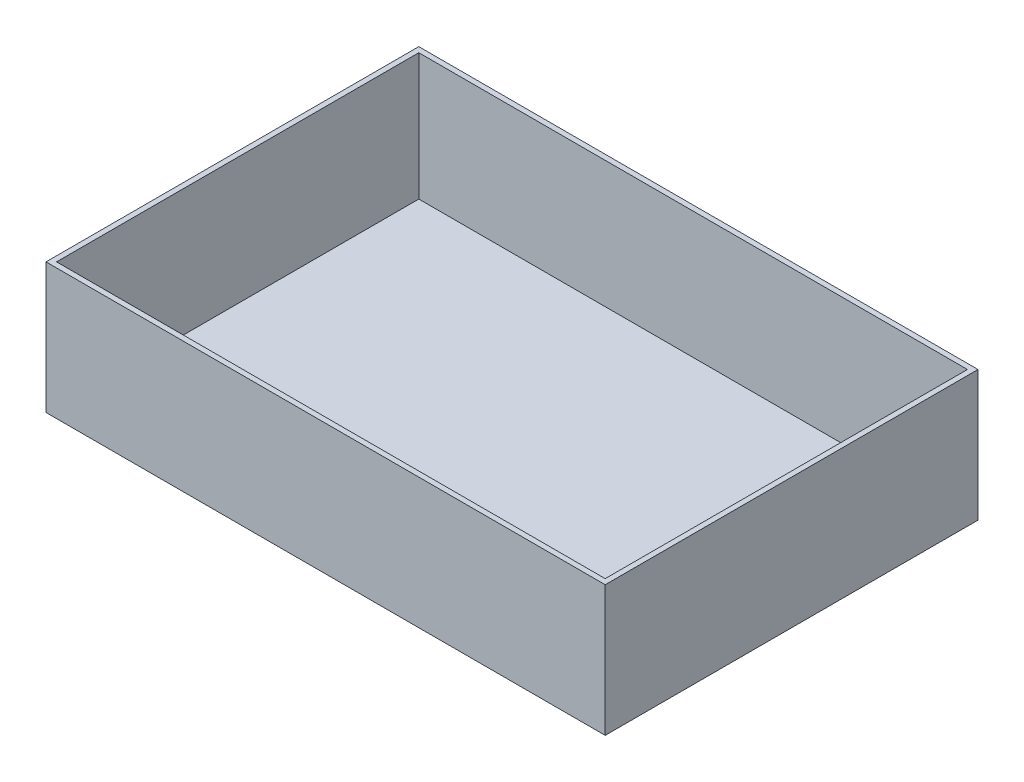
from build123d import *

# Parameters (mm, degrees)
SKETCH1_W           = 3000
SKETCH1_H           = 2000
SKETCH1_W_2         = 2943.431457506
SKETCH1_H_2         = 1943.431457506
BOSS_EXTRUDE2_DEPTH = 700
SKETCH2_W           = 2943.431457506
SKETCH2_H           = 1943.431457506
BOSS_EXTRUDE3_DEPTH = 20


with BuildPart() as part:
    # Sketch1 → Boss-Extrude2 (new body)
    with BuildSketch(Plane(origin=(0, 0, 0), x_dir=(1, 0, 0), z_dir=(0, 1, 0))):
        with Locations((1500, 1000)):
            Rectangle(SKETCH1_W, SKETCH1_H)
        with Locations((1500, 1000)):
            Rectangle(SKETCH1_W_2, SKETCH1_H_2, mode=Mode.SUBTRACT)
    extrude(amount=BOSS_EXTRUDE2_DEPTH)

    # Sketch2 → Boss-Extrude3 (add)
    with BuildSketch(Plane(origin=(0, 0, 0), x_dir=(1, 0, 0), z_dir=(0, 1, 0))):
        with Locations((1500, 1000)):
            Rectangle(SKETCH2_W, SKETCH2_H)
    extrude(amount=BOSS_EXTRUDE3_DEPTH)


solid = part.part
